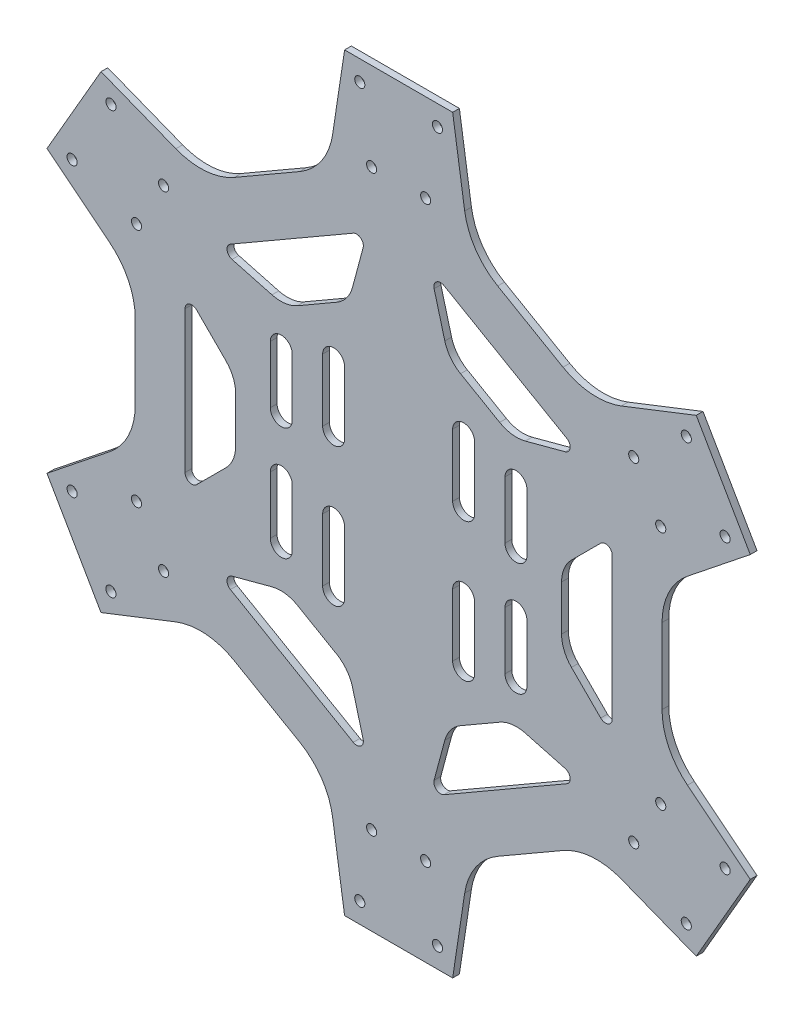
from build123d import *

# Parameters (mm, degrees)
BOSS_EXTRUDE1_DEPTH = 2
CUT_EXTRUDE1_REACH  = 4
CUT_EXTRUDE2_REACH  = 4
CUT_EXTRUDE3_REACH  = 4
SKETCH4_R           = 1.5


with BuildPart() as part:
    # Sketch1 → Boss-Extrude1 (new body)
    with BuildSketch(Plane.XY):
        with BuildLine():
            Line((88.12881982, 222), (84.568261253, 198.459214885))
            ThreePointArc((84.568261253, 198.459214885), (81.315061134, 190.17956792), (74.793177049, 184.129700743))
            Line((74.793177049, 184.129700743), (55.464462591, 172.970262248))
            ThreePointArc((55.464462591, 172.970262248), (46.964181884, 170.347078538), (38.167197219, 171.669548074))
            Line((38.167197219, 171.669548074), (16, 180.356406461))
            Line((16, 180.356406461), (0, 152.643593539))
            Line((0, 152.643593539), (18.606638651, 137.789666811))
            ThreePointArc((18.606638651, 137.789666811), (24.150423198, 130.832489382), (26.12881982, 122.159438495))
            Line((26.12881982, 122.159438495), (26.12881982, 99.840561505))
            ThreePointArc((26.12881982, 99.840561505), (24.150423198, 91.167510618), (18.606638651, 84.210333189))
            Line((18.606638651, 84.210333189), (0, 69.356406461))
            Line((0, 69.356406461), (16, 41.643593539))
            Line((16, 41.643593539), (38.167197219, 50.330451926))
            ThreePointArc((38.167197219, 50.330451926), (46.964181884, 51.652921462), (55.464462591, 49.029737752))
            Line((55.464462591, 49.029737752), (74.793177049, 37.870299257))
            ThreePointArc((74.793177049, 37.870299257), (81.315061134, 31.82043208), (84.568261253, 23.540785115))
            Line((84.568261253, 23.540785115), (88.12881982, 0))
            Line((88.12881982, 0), (120.12881982, 0))
            Line((120.12881982, 0), (123.689378387, 23.540785115))
            ThreePointArc((123.689378387, 23.540785115), (126.942578506, 31.82043208), (133.464462591, 37.870299257))
            Line((133.464462591, 37.870299257), (152.793177049, 49.029737752))
            ThreePointArc((152.793177049, 49.029737752), (161.293457756, 51.652921462), (170.090442422, 50.330451926))
            Line((170.090442422, 50.330451926), (192.25763964, 41.643593539))
            Line((192.25763964, 41.643593539), (208.25763964, 69.356406461))
            Line((208.25763964, 69.356406461), (189.651000989, 84.210333189))
            ThreePointArc((189.651000989, 84.210333189), (184.107216442, 91.167510618), (182.12881982, 99.840561505))
            Line((182.12881982, 99.840561505), (182.12881982, 122.159438495))
            ThreePointArc((182.12881982, 122.159438495), (184.107216442, 130.832489382), (189.651000989, 137.789666811))
            Line((189.651000989, 137.789666811), (208.25763964, 152.643593539))
            Line((208.25763964, 152.643593539), (192.25763964, 180.356406461))
            Line((192.25763964, 180.356406461), (170.090442422, 171.669548074))
            ThreePointArc((170.090442422, 171.669548074), (161.293457756, 170.347078538), (152.793177049, 172.970262248))
            Line((152.793177049, 172.970262248), (133.464462591, 184.129700743))
            ThreePointArc((133.464462591, 184.129700743), (126.942578506, 190.17956792), (123.689378387, 198.459214885))
            Line((123.689378387, 198.459214885), (120.12881982, 222))
            Line((120.12881982, 222), (88.12881982, 222))
        make_face()
    extrude(amount=BOSS_EXTRUDE1_DEPTH)

    # Sketch2 → Cut-Extrude1 (cut, up to next)
    with BuildSketch(Plane.XY.offset(2), mode=Mode.PRIVATE) as cut_extrude1_sk1:
        with BuildLine():
            Line((153.9403533, 155.276106789), (117.567286341, 176.276106789))
            ThreePointArc((117.567286341, 176.276106789), (115.349763483, 176.130762662), (114.635434688, 174.026417892))
            Line((114.635434688, 174.026417892), (117.80406326, 162.20093507))
            ThreePointArc((117.80406326, 162.20093507), (119.52978812, 158.701511231), (122.463321523, 156.128871483))
            Line((122.463321523, 156.128871483), (134.044318117, 149.442579982))
            ThreePointArc((134.044318117, 149.442579982), (137.739056195, 148.188385406), (141.632508568, 148.443575757))
            Line((141.632508568, 148.443575757), (153.45799139, 151.612204329))
            ThreePointArc((153.45799139, 151.612204329), (154.923243022, 153.283003597), (153.9403533, 155.276106789))
        make_face()
    cut_extrude1_tool1 = extrude(cut_extrude1_sk1.sketch, amount=-CUT_EXTRUDE1_REACH, mode=Mode.PRIVATE) & part.part
    add(cut_extrude1_tool1.solids().sort_by_distance((132.495552, 160.132622, 2))[0], mode=Mode.SUBTRACT)
    # Sketch2 → Cut-Extrude1 (cut, up to next)
    with BuildSketch(Plane.XY.offset(2), mode=Mode.PRIVATE) as cut_extrude1_sk2:
        with BuildLine():
            Line((152.37881982, 104.313708499), (152.37881982, 117.686291501))
            ThreePointArc((152.37881982, 117.686291501), (153.140024495, 121.513125825), (155.307752008, 124.757359313))
            Line((155.307752008, 124.757359313), (163.964606258, 133.414213562))
            ThreePointArc((163.964606258, 133.414213562), (166.144186685, 133.847759065), (167.37881982, 132))
            Line((167.37881982, 132), (167.37881982, 90))
            ThreePointArc((167.37881982, 90), (166.144186685, 88.152240935), (163.964606258, 88.585786438))
            Line((163.964606258, 88.585786438), (155.307752008, 97.242640687))
            ThreePointArc((155.307752008, 97.242640687), (153.140024495, 100.486874175), (152.37881982, 104.313708499))
        make_face()
    cut_extrude1_tool2 = extrude(cut_extrude1_sk2.sketch, amount=-CUT_EXTRUDE1_REACH, mode=Mode.PRIVATE) & part.part
    add(cut_extrude1_tool2.solids().sort_by_distance((160.862284, 111, 2))[0], mode=Mode.SUBTRACT)
    # Sketch2 → Cut-Extrude1 (cut, up to next)
    with BuildSketch(Plane.XY.offset(2), mode=Mode.PRIVATE) as cut_extrude1_sk3:
        with BuildLine():
            Line((122.463321523, 65.871128517), (134.044318117, 72.557420018))
            ThreePointArc((134.044318117, 72.557420018), (137.739056195, 73.811614594), (141.632508568, 73.556424243))
            Line((141.632508568, 73.556424243), (153.45799139, 70.387795671))
            ThreePointArc((153.45799139, 70.387795671), (154.923243022, 68.716996403), (153.9403533, 66.723893211))
            Line((153.9403533, 66.723893211), (117.567286341, 45.723893211))
            ThreePointArc((117.567286341, 45.723893211), (115.349763483, 45.869237338), (114.635434688, 47.973582108))
            Line((114.635434688, 47.973582108), (117.80406326, 59.79906493))
            ThreePointArc((117.80406326, 59.79906493), (119.52978812, 63.298488769), (122.463321523, 65.871128517))
        make_face()
    cut_extrude1_tool3 = extrude(cut_extrude1_sk3.sketch, amount=-CUT_EXTRUDE1_REACH, mode=Mode.PRIVATE) & part.part
    add(cut_extrude1_tool3.solids().sort_by_distance((132.495552, 61.867378, 2))[0], mode=Mode.SUBTRACT)
    # Sketch2 → Cut-Extrude1 (cut, up to next)
    with BuildSketch(Plane.XY.offset(2), mode=Mode.PRIVATE) as cut_extrude1_sk4:
        with BuildLine():
            Line((74.213321523, 72.557420018), (85.794318117, 65.871128517))
            ThreePointArc((85.794318117, 65.871128517), (88.72785152, 63.298488769), (90.45357638, 59.79906493))
            Line((90.45357638, 59.79906493), (93.622204952, 47.973582108))
            ThreePointArc((93.622204952, 47.973582108), (92.907876158, 45.869237338), (90.6903533, 45.723893211))
            Line((90.6903533, 45.723893211), (54.317286341, 66.723893211))
            ThreePointArc((54.317286341, 66.723893211), (53.334396618, 68.716996403), (54.79964825, 70.387795671))
            Line((54.79964825, 70.387795671), (66.625131072, 73.556424243))
            ThreePointArc((66.625131072, 73.556424243), (70.518583445, 73.811614594), (74.213321523, 72.557420018))
        make_face()
    cut_extrude1_tool4 = extrude(cut_extrude1_sk4.sketch, amount=-CUT_EXTRUDE1_REACH, mode=Mode.PRIVATE) & part.part
    add(cut_extrude1_tool4.solids().sort_by_distance((75.762088, 61.867378, 2))[0], mode=Mode.SUBTRACT)
    # Sketch2 → Cut-Extrude1 (cut, up to next)
    with BuildSketch(Plane.XY.offset(2), mode=Mode.PRIVATE) as cut_extrude1_sk5:
        with BuildLine():
            Line((55.87881982, 117.686291501), (55.87881982, 104.313708499))
            ThreePointArc((55.87881982, 104.313708499), (55.117615145, 100.486874175), (52.949887632, 97.242640687))
            Line((52.949887632, 97.242640687), (44.293033382, 88.585786438))
            ThreePointArc((44.293033382, 88.585786438), (42.113452955, 88.152240935), (40.87881982, 90))
            Line((40.87881982, 90), (40.87881982, 132))
            ThreePointArc((40.87881982, 132), (42.113452955, 133.847759065), (44.293033382, 133.414213562))
            Line((44.293033382, 133.414213562), (52.949887632, 124.757359313))
            ThreePointArc((52.949887632, 124.757359313), (55.117615145, 121.513125825), (55.87881982, 117.686291501))
        make_face()
    cut_extrude1_tool5 = extrude(cut_extrude1_sk5.sketch, amount=-CUT_EXTRUDE1_REACH, mode=Mode.PRIVATE) & part.part
    add(cut_extrude1_tool5.solids().sort_by_distance((47.395355, 111, 2))[0], mode=Mode.SUBTRACT)
    # Sketch2 → Cut-Extrude1 (cut, up to next)
    with BuildSketch(Plane.XY.offset(2), mode=Mode.PRIVATE) as cut_extrude1_sk6:
        with BuildLine():
            Line((85.794318117, 156.128871483), (74.213321523, 149.442579982))
            ThreePointArc((74.213321523, 149.442579982), (70.518583445, 148.188385406), (66.625131072, 148.443575757))
            Line((66.625131072, 148.443575757), (54.79964825, 151.612204329))
            ThreePointArc((54.79964825, 151.612204329), (53.334396618, 153.283003597), (54.317286341, 155.276106789))
            Line((54.317286341, 155.276106789), (90.6903533, 176.276106789))
            ThreePointArc((90.6903533, 176.276106789), (92.907876158, 176.130762662), (93.622204952, 174.026417892))
            Line((93.622204952, 174.026417892), (90.45357638, 162.20093507))
            ThreePointArc((90.45357638, 162.20093507), (88.72785152, 158.701511231), (85.794318117, 156.128871483))
        make_face()
    cut_extrude1_tool6 = extrude(cut_extrude1_sk6.sketch, amount=-CUT_EXTRUDE1_REACH, mode=Mode.PRIVATE) & part.part
    add(cut_extrude1_tool6.solids().sort_by_distance((75.762088, 160.132622, 2))[0], mode=Mode.SUBTRACT)

    # Sketch3 → Cut-Extrude2 (cut, up to next)
    with BuildSketch(Plane.XY.offset(2), mode=Mode.PRIVATE) as cut_extrude2_sk1:
        with BuildLine():
            Line((72.62881982, 136.25), (72.62881982, 119.25))
            ThreePointArc((72.62881982, 119.25), (69.37881982, 116), (66.12881982, 119.25))
            Line((66.12881982, 119.25), (66.12881982, 136.25))
            ThreePointArc((66.12881982, 136.25), (69.37881982, 139.5), (72.62881982, 136.25))
        make_face()
    cut_extrude2_tool1 = extrude(cut_extrude2_sk1.sketch, amount=-CUT_EXTRUDE2_REACH, mode=Mode.PRIVATE) & part.part
    add(cut_extrude2_tool1.solids().sort_by_distance((69.37882, 127.75, 2))[0], mode=Mode.SUBTRACT)
    # Sketch3 → Cut-Extrude2 (cut, up to next)
    with BuildSketch(Plane.XY.offset(2), mode=Mode.PRIVATE) as cut_extrude2_sk2:
        with BuildLine():
            Line((88.12881982, 140.75), (88.12881982, 122.25))
            ThreePointArc((88.12881982, 122.25), (84.87881982, 119), (81.62881982, 122.25))
            Line((81.62881982, 122.25), (81.62881982, 140.75))
            ThreePointArc((81.62881982, 140.75), (84.87881982, 144), (88.12881982, 140.75))
        make_face()
    cut_extrude2_tool2 = extrude(cut_extrude2_sk2.sketch, amount=-CUT_EXTRUDE2_REACH, mode=Mode.PRIVATE) & part.part
    add(cut_extrude2_tool2.solids().sort_by_distance((84.87882, 131.5, 2))[0], mode=Mode.SUBTRACT)
    # Sketch3 → Cut-Extrude2 (cut, up to next)
    with BuildSketch(Plane.XY.offset(2), mode=Mode.PRIVATE) as cut_extrude2_sk3:
        with BuildLine():
            Line((72.62881982, 102.75), (72.62881982, 85.75))
            ThreePointArc((72.62881982, 85.75), (69.37881982, 82.5), (66.12881982, 85.75))
            Line((66.12881982, 85.75), (66.12881982, 102.75))
            ThreePointArc((66.12881982, 102.75), (69.37881982, 106), (72.62881982, 102.75))
        make_face()
    cut_extrude2_tool3 = extrude(cut_extrude2_sk3.sketch, amount=-CUT_EXTRUDE2_REACH, mode=Mode.PRIVATE) & part.part
    add(cut_extrude2_tool3.solids().sort_by_distance((69.37882, 94.25, 2))[0], mode=Mode.SUBTRACT)
    # Sketch3 → Cut-Extrude2 (cut, up to next)
    with BuildSketch(Plane.XY.offset(2), mode=Mode.PRIVATE) as cut_extrude2_sk4:
        with BuildLine():
            Line((88.12881982, 99.75), (88.12881982, 81.25))
            ThreePointArc((88.12881982, 81.25), (84.87881982, 78), (81.62881982, 81.25))
            Line((81.62881982, 81.25), (81.62881982, 99.75))
            ThreePointArc((81.62881982, 99.75), (84.87881982, 103), (88.12881982, 99.75))
        make_face()
    cut_extrude2_tool4 = extrude(cut_extrude2_sk4.sketch, amount=-CUT_EXTRUDE2_REACH, mode=Mode.PRIVATE) & part.part
    add(cut_extrude2_tool4.solids().sort_by_distance((84.87882, 90.5, 2))[0], mode=Mode.SUBTRACT)
    # Sketch3 → Cut-Extrude2 (cut, up to next)
    with BuildSketch(Plane.XY.offset(2), mode=Mode.PRIVATE) as cut_extrude2_sk5:
        with BuildLine():
            Line((120.12881982, 99.75), (120.12881982, 81.25))
            ThreePointArc((120.12881982, 81.25), (123.37881982, 78), (126.62881982, 81.25))
            Line((126.62881982, 81.25), (126.62881982, 99.75))
            ThreePointArc((126.62881982, 99.75), (123.37881982, 103), (120.12881982, 99.75))
        make_face()
    cut_extrude2_tool5 = extrude(cut_extrude2_sk5.sketch, amount=-CUT_EXTRUDE2_REACH, mode=Mode.PRIVATE) & part.part
    add(cut_extrude2_tool5.solids().sort_by_distance((123.37882, 90.5, 2))[0], mode=Mode.SUBTRACT)
    # Sketch3 → Cut-Extrude2 (cut, up to next)
    with BuildSketch(Plane.XY.offset(2), mode=Mode.PRIVATE) as cut_extrude2_sk6:
        with BuildLine():
            Line((135.62881982, 102.75), (135.62881982, 85.75))
            ThreePointArc((135.62881982, 85.75), (138.87881982, 82.5), (142.12881982, 85.75))
            Line((142.12881982, 85.75), (142.12881982, 102.75))
            ThreePointArc((142.12881982, 102.75), (138.87881982, 106), (135.62881982, 102.75))
        make_face()
    cut_extrude2_tool6 = extrude(cut_extrude2_sk6.sketch, amount=-CUT_EXTRUDE2_REACH, mode=Mode.PRIVATE) & part.part
    add(cut_extrude2_tool6.solids().sort_by_distance((138.87882, 94.25, 2))[0], mode=Mode.SUBTRACT)
    # Sketch3 → Cut-Extrude2 (cut, up to next)
    with BuildSketch(Plane.XY.offset(2), mode=Mode.PRIVATE) as cut_extrude2_sk7:
        with BuildLine():
            Line((120.12881982, 140.75), (120.12881982, 122.25))
            ThreePointArc((120.12881982, 122.25), (123.37881982, 119), (126.62881982, 122.25))
            Line((126.62881982, 122.25), (126.62881982, 140.75))
            ThreePointArc((126.62881982, 140.75), (123.37881982, 144), (120.12881982, 140.75))
        make_face()
    cut_extrude2_tool7 = extrude(cut_extrude2_sk7.sketch, amount=-CUT_EXTRUDE2_REACH, mode=Mode.PRIVATE) & part.part
    add(cut_extrude2_tool7.solids().sort_by_distance((123.37882, 131.5, 2))[0], mode=Mode.SUBTRACT)
    # Sketch3 → Cut-Extrude2 (cut, up to next)
    with BuildSketch(Plane.XY.offset(2), mode=Mode.PRIVATE) as cut_extrude2_sk8:
        with BuildLine():
            Line((135.62881982, 136.25), (135.62881982, 119.25))
            ThreePointArc((135.62881982, 119.25), (138.87881982, 116), (142.12881982, 119.25))
            Line((142.12881982, 119.25), (142.12881982, 136.25))
            ThreePointArc((142.12881982, 136.25), (138.87881982, 139.5), (135.62881982, 136.25))
        make_face()
    cut_extrude2_tool8 = extrude(cut_extrude2_sk8.sketch, amount=-CUT_EXTRUDE2_REACH, mode=Mode.PRIVATE) & part.part
    add(cut_extrude2_tool8.solids().sort_by_distance((138.87882, 127.75, 2))[0], mode=Mode.SUBTRACT)

    # Sketch4 → Cut-Extrude3 (cut, up to next)
    with BuildSketch(Plane.XY.offset(2), mode=Mode.PRIVATE) as cut_extrude3_sk1:
        with Locations((92.62881982, 216)):
            Circle(SKETCH4_R)
    cut_extrude3_tool1 = extrude(cut_extrude3_sk1.sketch, amount=-CUT_EXTRUDE3_REACH, mode=Mode.PRIVATE) & part.part
    add(cut_extrude3_tool1.solids().sort_by_distance((92.62882, 216, 2))[0], mode=Mode.SUBTRACT)
    # Sketch4 → Cut-Extrude3 (cut, up to next)
    with BuildSketch(Plane.XY.offset(2), mode=Mode.PRIVATE) as cut_extrude3_sk2:
        with Locations((115.62881982, 216)):
            Circle(SKETCH4_R)
    cut_extrude3_tool2 = extrude(cut_extrude3_sk2.sketch, amount=-CUT_EXTRUDE3_REACH, mode=Mode.PRIVATE) & part.part
    add(cut_extrude3_tool2.solids().sort_by_distance((115.62882, 216, 2))[0], mode=Mode.SUBTRACT)
    # Sketch4 → Cut-Extrude3 (cut, up to next)
    with BuildSketch(Plane.XY.offset(2), mode=Mode.PRIVATE) as cut_extrude3_sk3:
        with Locations((96.12881982, 196)):
            Circle(SKETCH4_R)
    cut_extrude3_tool3 = extrude(cut_extrude3_sk3.sketch, amount=-CUT_EXTRUDE3_REACH, mode=Mode.PRIVATE) & part.part
    add(cut_extrude3_tool3.solids().sort_by_distance((96.12882, 196, 2))[0], mode=Mode.SUBTRACT)
    # Sketch4 → Cut-Extrude3 (cut, up to next)
    with BuildSketch(Plane.XY.offset(2), mode=Mode.PRIVATE) as cut_extrude3_sk4:
        with Locations((112.12881982, 196)):
            Circle(SKETCH4_R)
    cut_extrude3_tool4 = extrude(cut_extrude3_sk4.sketch, amount=-CUT_EXTRUDE3_REACH, mode=Mode.PRIVATE) & part.part
    add(cut_extrude3_tool4.solids().sort_by_distance((112.12882, 196, 2))[0], mode=Mode.SUBTRACT)
    # Sketch4 → Cut-Extrude3 (cut, up to next)
    with BuildSketch(Plane.XY.offset(2), mode=Mode.PRIVATE) as cut_extrude3_sk5:
        with Locations((173.740979142, 160.42820323)):
            Circle(SKETCH4_R)
    cut_extrude3_tool5 = extrude(cut_extrude3_sk5.sketch, amount=-CUT_EXTRUDE3_REACH, mode=Mode.PRIVATE) & part.part
    add(cut_extrude3_tool5.solids().sort_by_distance((173.740979, 160.428203, 2))[0], mode=Mode.SUBTRACT)
    # Sketch4 → Cut-Extrude3 (cut, up to next)
    with BuildSketch(Plane.XY.offset(2), mode=Mode.PRIVATE) as cut_extrude3_sk6:
        with Locations((181.740979142, 146.57179677)):
            Circle(SKETCH4_R)
    cut_extrude3_tool6 = extrude(cut_extrude3_sk6.sketch, amount=-CUT_EXTRUDE3_REACH, mode=Mode.PRIVATE) & part.part
    add(cut_extrude3_tool6.solids().sort_by_distance((181.740979, 146.571797, 2))[0], mode=Mode.SUBTRACT)
    # Sketch4 → Cut-Extrude3 (cut, up to next)
    with BuildSketch(Plane.XY.offset(2), mode=Mode.PRIVATE) as cut_extrude3_sk7:
        with Locations((200.811487217, 153.540707856)):
            Circle(SKETCH4_R)
    cut_extrude3_tool7 = extrude(cut_extrude3_sk7.sketch, amount=-CUT_EXTRUDE3_REACH, mode=Mode.PRIVATE) & part.part
    add(cut_extrude3_tool7.solids().sort_by_distance((200.811487, 153.540708, 2))[0], mode=Mode.SUBTRACT)
    # Sketch4 → Cut-Extrude3 (cut, up to next)
    with BuildSketch(Plane.XY.offset(2), mode=Mode.PRIVATE) as cut_extrude3_sk8:
        with Locations((189.311487217, 173.459292144)):
            Circle(SKETCH4_R)
    cut_extrude3_tool8 = extrude(cut_extrude3_sk8.sketch, amount=-CUT_EXTRUDE3_REACH, mode=Mode.PRIVATE) & part.part
    add(cut_extrude3_tool8.solids().sort_by_distance((189.311487, 173.459292, 2))[0], mode=Mode.SUBTRACT)
    # Sketch4 → Cut-Extrude3 (cut, up to next)
    with BuildSketch(Plane.XY.offset(2), mode=Mode.PRIVATE) as cut_extrude3_sk9:
        with Locations((181.740979142, 75.42820323)):
            Circle(SKETCH4_R)
    cut_extrude3_tool9 = extrude(cut_extrude3_sk9.sketch, amount=-CUT_EXTRUDE3_REACH, mode=Mode.PRIVATE) & part.part
    add(cut_extrude3_tool9.solids().sort_by_distance((181.740979, 75.428203, 2))[0], mode=Mode.SUBTRACT)
    # Sketch4 → Cut-Extrude3 (cut, up to next)
    with BuildSketch(Plane.XY.offset(2), mode=Mode.PRIVATE) as cut_extrude3_sk10:
        with Locations((173.740979142, 61.57179677)):
            Circle(SKETCH4_R)
    cut_extrude3_tool10 = extrude(cut_extrude3_sk10.sketch, amount=-CUT_EXTRUDE3_REACH, mode=Mode.PRIVATE) & part.part
    add(cut_extrude3_tool10.solids().sort_by_distance((173.740979, 61.571797, 2))[0], mode=Mode.SUBTRACT)
    # Sketch4 → Cut-Extrude3 (cut, up to next)
    with BuildSketch(Plane.XY.offset(2), mode=Mode.PRIVATE) as cut_extrude3_sk11:
        with Locations((189.311487217, 48.540707856)):
            Circle(SKETCH4_R)
    cut_extrude3_tool11 = extrude(cut_extrude3_sk11.sketch, amount=-CUT_EXTRUDE3_REACH, mode=Mode.PRIVATE) & part.part
    add(cut_extrude3_tool11.solids().sort_by_distance((189.311487, 48.540708, 2))[0], mode=Mode.SUBTRACT)
    # Sketch4 → Cut-Extrude3 (cut, up to next)
    with BuildSketch(Plane.XY.offset(2), mode=Mode.PRIVATE) as cut_extrude3_sk12:
        with Locations((200.811487217, 68.459292144)):
            Circle(SKETCH4_R)
    cut_extrude3_tool12 = extrude(cut_extrude3_sk12.sketch, amount=-CUT_EXTRUDE3_REACH, mode=Mode.PRIVATE) & part.part
    add(cut_extrude3_tool12.solids().sort_by_distance((200.811487, 68.459292, 2))[0], mode=Mode.SUBTRACT)
    # Sketch4 → Cut-Extrude3 (cut, up to next)
    with BuildSketch(Plane.XY.offset(2), mode=Mode.PRIVATE) as cut_extrude3_sk13:
        with Locations((112.12881982, 26)):
            Circle(SKETCH4_R)
    cut_extrude3_tool13 = extrude(cut_extrude3_sk13.sketch, amount=-CUT_EXTRUDE3_REACH, mode=Mode.PRIVATE) & part.part
    add(cut_extrude3_tool13.solids().sort_by_distance((112.12882, 26, 2))[0], mode=Mode.SUBTRACT)
    # Sketch4 → Cut-Extrude3 (cut, up to next)
    with BuildSketch(Plane.XY.offset(2), mode=Mode.PRIVATE) as cut_extrude3_sk14:
        with Locations((96.12881982, 26)):
            Circle(SKETCH4_R)
    cut_extrude3_tool14 = extrude(cut_extrude3_sk14.sketch, amount=-CUT_EXTRUDE3_REACH, mode=Mode.PRIVATE) & part.part
    add(cut_extrude3_tool14.solids().sort_by_distance((96.12882, 26, 2))[0], mode=Mode.SUBTRACT)
    # Sketch4 → Cut-Extrude3 (cut, up to next)
    with BuildSketch(Plane.XY.offset(2), mode=Mode.PRIVATE) as cut_extrude3_sk15:
        with Locations((92.62881982, 6)):
            Circle(SKETCH4_R)
    cut_extrude3_tool15 = extrude(cut_extrude3_sk15.sketch, amount=-CUT_EXTRUDE3_REACH, mode=Mode.PRIVATE) & part.part
    add(cut_extrude3_tool15.solids().sort_by_distance((92.62882, 6, 2))[0], mode=Mode.SUBTRACT)
    # Sketch4 → Cut-Extrude3 (cut, up to next)
    with BuildSketch(Plane.XY.offset(2), mode=Mode.PRIVATE) as cut_extrude3_sk16:
        with Locations((115.62881982, 6)):
            Circle(SKETCH4_R)
    cut_extrude3_tool16 = extrude(cut_extrude3_sk16.sketch, amount=-CUT_EXTRUDE3_REACH, mode=Mode.PRIVATE) & part.part
    add(cut_extrude3_tool16.solids().sort_by_distance((115.62882, 6, 2))[0], mode=Mode.SUBTRACT)
    # Sketch4 → Cut-Extrude3 (cut, up to next)
    with BuildSketch(Plane.XY.offset(2), mode=Mode.PRIVATE) as cut_extrude3_sk17:
        with Locations((34.516660498, 61.57179677)):
            Circle(SKETCH4_R)
    cut_extrude3_tool17 = extrude(cut_extrude3_sk17.sketch, amount=-CUT_EXTRUDE3_REACH, mode=Mode.PRIVATE) & part.part
    add(cut_extrude3_tool17.solids().sort_by_distance((34.51666, 61.571797, 2))[0], mode=Mode.SUBTRACT)
    # Sketch4 → Cut-Extrude3 (cut, up to next)
    with BuildSketch(Plane.XY.offset(2), mode=Mode.PRIVATE) as cut_extrude3_sk18:
        with Locations((26.516660498, 75.42820323)):
            Circle(SKETCH4_R)
    cut_extrude3_tool18 = extrude(cut_extrude3_sk18.sketch, amount=-CUT_EXTRUDE3_REACH, mode=Mode.PRIVATE) & part.part
    add(cut_extrude3_tool18.solids().sort_by_distance((26.51666, 75.428203, 2))[0], mode=Mode.SUBTRACT)
    # Sketch4 → Cut-Extrude3 (cut, up to next)
    with BuildSketch(Plane.XY.offset(2), mode=Mode.PRIVATE) as cut_extrude3_sk19:
        with Locations((7.446152423, 68.459292144)):
            Circle(SKETCH4_R)
    cut_extrude3_tool19 = extrude(cut_extrude3_sk19.sketch, amount=-CUT_EXTRUDE3_REACH, mode=Mode.PRIVATE) & part.part
    add(cut_extrude3_tool19.solids().sort_by_distance((7.446152, 68.459292, 2))[0], mode=Mode.SUBTRACT)
    # Sketch4 → Cut-Extrude3 (cut, up to next)
    with BuildSketch(Plane.XY.offset(2), mode=Mode.PRIVATE) as cut_extrude3_sk20:
        with Locations((18.946152423, 48.540707856)):
            Circle(SKETCH4_R)
    cut_extrude3_tool20 = extrude(cut_extrude3_sk20.sketch, amount=-CUT_EXTRUDE3_REACH, mode=Mode.PRIVATE) & part.part
    add(cut_extrude3_tool20.solids().sort_by_distance((18.946152, 48.540708, 2))[0], mode=Mode.SUBTRACT)
    # Sketch4 → Cut-Extrude3 (cut, up to next)
    with BuildSketch(Plane.XY.offset(2), mode=Mode.PRIVATE) as cut_extrude3_sk21:
        with Locations((26.516660498, 146.57179677)):
            Circle(SKETCH4_R)
    cut_extrude3_tool21 = extrude(cut_extrude3_sk21.sketch, amount=-CUT_EXTRUDE3_REACH, mode=Mode.PRIVATE) & part.part
    add(cut_extrude3_tool21.solids().sort_by_distance((26.51666, 146.571797, 2))[0], mode=Mode.SUBTRACT)
    # Sketch4 → Cut-Extrude3 (cut, up to next)
    with BuildSketch(Plane.XY.offset(2), mode=Mode.PRIVATE) as cut_extrude3_sk22:
        with Locations((34.516660498, 160.42820323)):
            Circle(SKETCH4_R)
    cut_extrude3_tool22 = extrude(cut_extrude3_sk22.sketch, amount=-CUT_EXTRUDE3_REACH, mode=Mode.PRIVATE) & part.part
    add(cut_extrude3_tool22.solids().sort_by_distance((34.51666, 160.428203, 2))[0], mode=Mode.SUBTRACT)
    # Sketch4 → Cut-Extrude3 (cut, up to next)
    with BuildSketch(Plane.XY.offset(2), mode=Mode.PRIVATE) as cut_extrude3_sk23:
        with Locations((18.946152423, 173.459292144)):
            Circle(SKETCH4_R)
    cut_extrude3_tool23 = extrude(cut_extrude3_sk23.sketch, amount=-CUT_EXTRUDE3_REACH, mode=Mode.PRIVATE) & part.part
    add(cut_extrude3_tool23.solids().sort_by_distance((18.946152, 173.459292, 2))[0], mode=Mode.SUBTRACT)
    # Sketch4 → Cut-Extrude3 (cut, up to next)
    with BuildSketch(Plane.XY.offset(2), mode=Mode.PRIVATE) as cut_extrude3_sk24:
        with Locations((7.446152423, 153.540707856)):
            Circle(SKETCH4_R)
    cut_extrude3_tool24 = extrude(cut_extrude3_sk24.sketch, amount=-CUT_EXTRUDE3_REACH, mode=Mode.PRIVATE) & part.part
    add(cut_extrude3_tool24.solids().sort_by_distance((7.446152, 153.540708, 2))[0], mode=Mode.SUBTRACT)


solid = part.part
